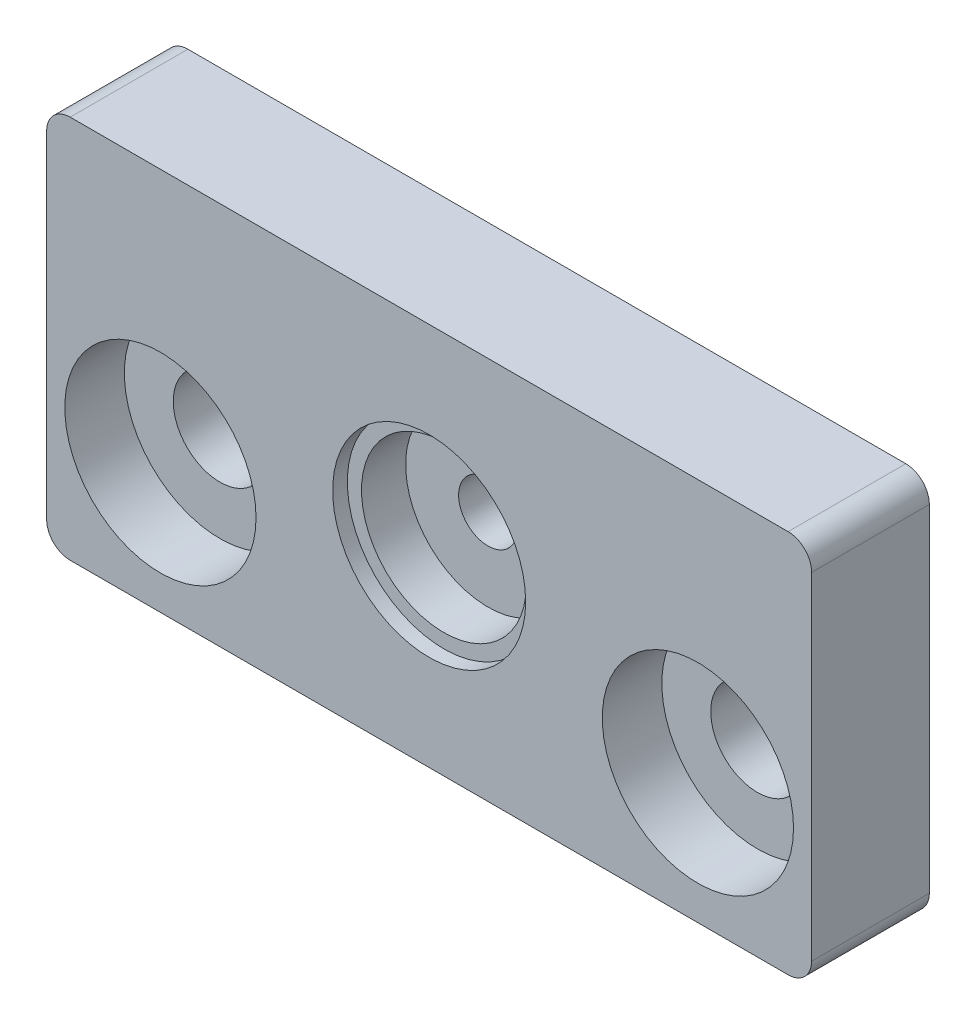
from build123d import *

# Parameters (mm, degrees)
SKETCH1_W                                            = 82.55
SKETCH1_H                                            = 41.4147
BOSS_EXTRUDE1_DEPTH                                  = 12.7
SKETCH2_R                                            = 3.175
CUT_EXTRUDE1_DEPTH                                   = 12.7
SKETCH3_R                                            = 8.89
CUT_EXTRUDE2_DEPTH                                   = 6.35
SKETCH5_R                                            = 10.414
CUT_EXTRUDE7_DEPTH                                   = 1.5875
FILLET1_R                                            = 2.54
CBORE_FOR_3_8_BINDING_HEAD_MACHINE_SCREW_D           = 10.0838
CBORE_FOR_3_8_BINDING_HEAD_MACHINE_SCREW_CBORE_D     = 20.6375
CBORE_FOR_3_8_BINDING_HEAD_MACHINE_SCREW_CBORE_DEPTH = 6.4262


with BuildPart() as part:
    # Sketch1 → Boss-Extrude1 (new body)
    with BuildSketch(Plane.XY):
        Rectangle(SKETCH1_W, SKETCH1_H)
    extrude(amount=BOSS_EXTRUDE1_DEPTH)

    # Sketch2 → Cut-Extrude1 (cut)
    with BuildSketch(Plane.XY.offset(12.7)):
        Circle(SKETCH2_R)
    extrude(amount=-CUT_EXTRUDE1_DEPTH, mode=Mode.SUBTRACT)

    # Sketch3 → Cut-Extrude2 (cut)
    with BuildSketch(Plane.XY.offset(12.7)):
        Circle(SKETCH3_R)
    extrude(amount=-CUT_EXTRUDE2_DEPTH, mode=Mode.SUBTRACT)

    # Sketch5 → Cut-Extrude7 (cut)
    with BuildSketch(Plane.XY.offset(12.7)):
        Circle(SKETCH5_R)
    extrude(amount=-CUT_EXTRUDE7_DEPTH, mode=Mode.SUBTRACT)

    # Fillet1
    fillet1_edges = [part.edges().sort_by_distance(p)[0] for p in [
        (41.275, -20.70735, 6.35),
        (-41.275, -20.70735, 6.35),
        (-41.275, 20.70735, 6.35),
        (41.275, 20.70735, 6.35),
    ]]
    fillet(fillet1_edges, radius=FILLET1_R)

    # CBORE for 3/8 Binding Head Machine Screw1 (through all)
    with Locations(Plane.XY.offset(12.7)):
        with Locations((-29, -6.708000046), (29, -6.708000046)):
            CounterBoreHole(CBORE_FOR_3_8_BINDING_HEAD_MACHINE_SCREW_D / 2, CBORE_FOR_3_8_BINDING_HEAD_MACHINE_SCREW_CBORE_D / 2, CBORE_FOR_3_8_BINDING_HEAD_MACHINE_SCREW_CBORE_DEPTH)


solid = part.part
